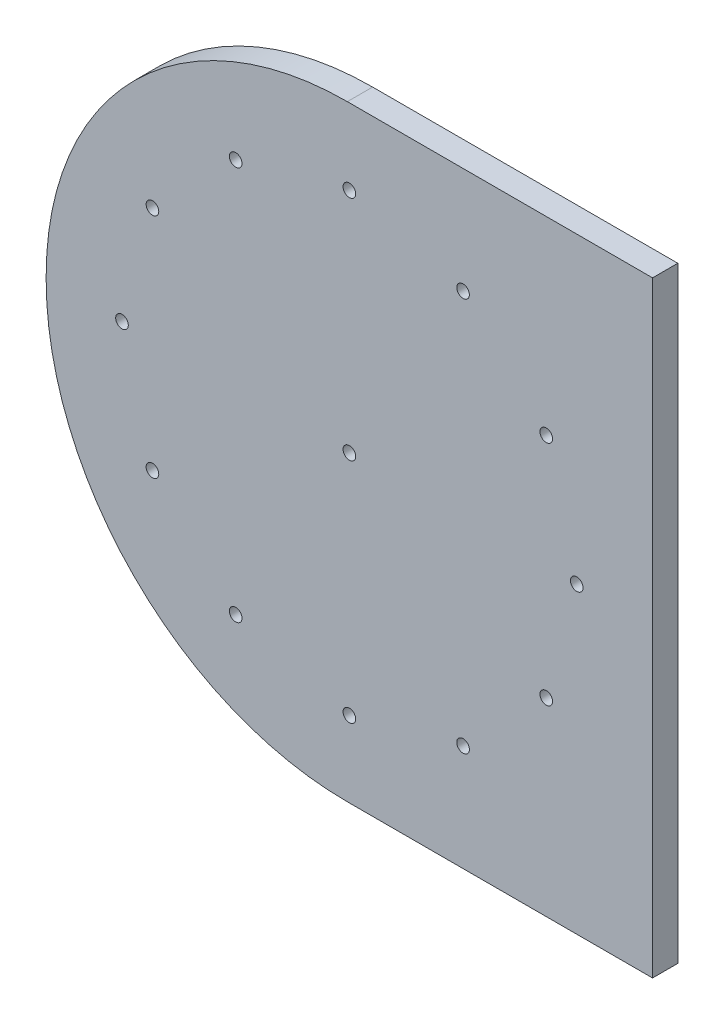
from build123d import *

# Parameters (mm, degrees)
BOSS_EXTRUDE1_DEPTH = 3.175
SKETCH5_R           = 0.79375
CUT_EXTRUDE10_DEPTH = 19.05


with BuildPart() as part:
    # Sketch2 → Boss-Extrude1 (new body)
    with BuildSketch(Plane.XY):
        with BuildLine():
            Line((76.2, 0), (76.2, -76.2))
            Line((76.2, -76.2), (37.846, -76.2))
            ThreePointArc((37.846, -76.2), (11.084836759, -65.115163241), (0, -38.354))
            Line((0, -38.354), (0, -37.846))
            ThreePointArc((0, -37.846), (11.084836759, -11.084836759), (37.846, 0))
            Line((37.846, 0), (76.2, 0))
        make_face()
    extrude(amount=BOSS_EXTRUDE1_DEPTH)

    # Sketch5 → Cut-Extrude10 (cut)
    with BuildSketch(Plane.XY):
        with Locations((38.1, -38.1)):
            Circle(SKETCH5_R)
        with Locations((66.675, -38.1)):
            Circle(SKETCH5_R)
        with Locations((62.846675913, -52.3875)):
            Circle(SKETCH5_R)
        with Locations((52.3875, -62.846675913)):
            Circle(SKETCH5_R)
        with Locations((38.1, -66.675)):
            Circle(SKETCH5_R)
        with Locations((23.8125, -62.846675913)):
            Circle(SKETCH5_R)
        with Locations((13.353324087, -52.3875)):
            Circle(SKETCH5_R)
        with Locations((9.525, -38.1)):
            Circle(SKETCH5_R)
        with Locations((13.353324087, -23.8125)):
            Circle(SKETCH5_R)
        with Locations((23.8125, -13.353324087)):
            Circle(SKETCH5_R)
        with Locations((38.1, -9.525)):
            Circle(SKETCH5_R)
        with Locations((52.3875, -13.353324087)):
            Circle(SKETCH5_R)
        with Locations((62.846675913, -23.8125)):
            Circle(SKETCH5_R)
    extrude(amount=CUT_EXTRUDE10_DEPTH, mode=Mode.SUBTRACT)


solid = part.part
